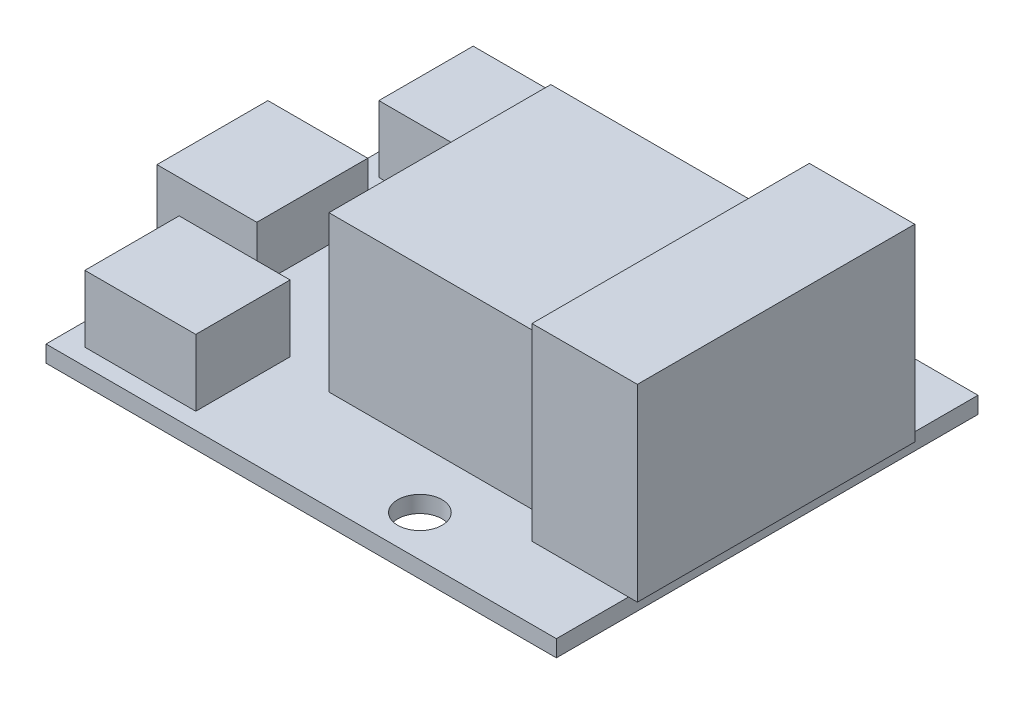
from build123d import *

# Parameters (mm, degrees)
ESBO_O1_W                = 46
ESBO_O1_H                = 38
ESBO_O1_R                = 2
RESSALTO_EXTRUS_O1_DEPTH = 1.5
ESBO_O2_W                = 9
ESBO_O2_H                = 10
RESSALTO_EXTRUS_O2_DEPTH = 5
ESBO_O2_3_W              = 10
ESBO_O2_3_H              = 8.5
RESSALTO_EXTRUS_O3_DEPTH = 6
ESBO_O2_4_W              = 20
ESBO_O2_4_H              = 20
RESSALTO_EXTRUS_O4_DEPTH = 14
ESBO_O2_5_W              = 9.5
ESBO_O2_5_H              = 25
RESSALTO_EXTRUS_O5_DEPTH = 17


with BuildPart() as part:
    # Esboço1 → Ressalto-extrusão1 (new body)
    with BuildSketch(Plane(origin=(0, 0, 0), x_dir=(1, 0, 0), z_dir=(0, 1, 0))):
        Rectangle(ESBO_O1_W, ESBO_O1_H)
        with Locations((7, -15.3)):
            Circle(ESBO_O1_R, mode=Mode.SUBTRACT)
        with Locations((7, 15.3)):
            Circle(ESBO_O1_R, mode=Mode.SUBTRACT)
    extrude(amount=RESSALTO_EXTRUS_O1_DEPTH)

    # Esboço2 → Ressalto-extrusão2 (add)
    with BuildSketch(Plane(origin=(0, 1.5, 0), x_dir=(1, 0, 0), z_dir=(0, 1, 0))):
        with Locations((-22.5, 0)):
            Rectangle(ESBO_O2_W, ESBO_O2_H)
    extrude(amount=RESSALTO_EXTRUS_O2_DEPTH)

    # Esboço2<3> → Ressalto-extrusão3 (add)
    with BuildSketch(Plane(origin=(0, 1.5, 0), x_dir=(1, 0, 0), z_dir=(0, 1, 0))):
        with Locations((-16, -13.25)):
            Rectangle(ESBO_O2_3_W, ESBO_O2_3_H)
        with Locations((-16, 13.25)):
            Rectangle(ESBO_O2_3_W, ESBO_O2_3_H)
    extrude(amount=RESSALTO_EXTRUS_O3_DEPTH)

    # Esboço2<4> → Ressalto-extrusão4 (add)
    with BuildSketch(Plane(origin=(0, 1.5, 0), x_dir=(1, 0, 0), z_dir=(0, 1, 0))):
        with Locations((3.5, 0)):
            Rectangle(ESBO_O2_4_W, ESBO_O2_4_H)
    extrude(amount=RESSALTO_EXTRUS_O4_DEPTH)

    # Esboço2<5> → Ressalto-extrusão5 (add)
    with BuildSketch(Plane(origin=(0, 1.5, 0), x_dir=(1, 0, 0), z_dir=(0, 1, 0))):
        with Locations((19.05, 0)):
            Rectangle(ESBO_O2_5_W, ESBO_O2_5_H)
    extrude(amount=RESSALTO_EXTRUS_O5_DEPTH)


solid = part.part
